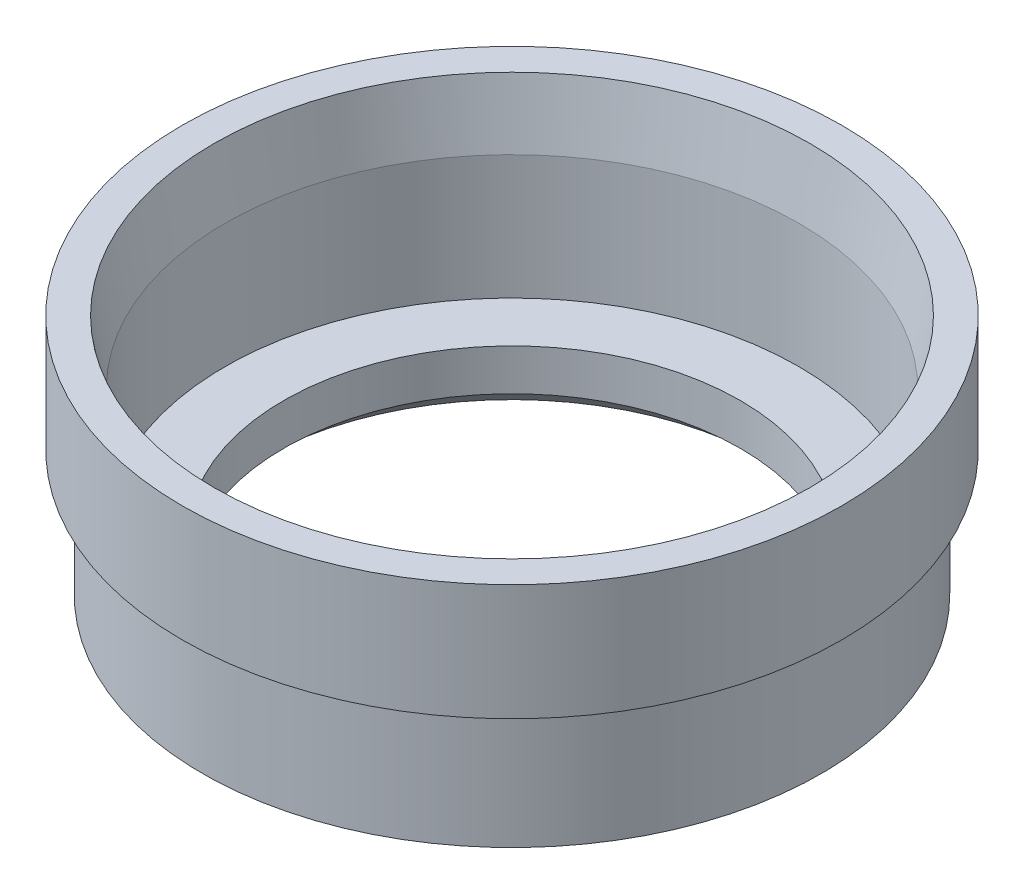
from build123d import *


with BuildPart() as part:
    # Sketch2 → Revolve1 (revolve)
    with BuildSketch(Plane.XY):
        Polygon((0, 8.639461868), (0, 5.245589646), (2.296170187, 3.205597118), (3.796170187, 3.205597118), (3.796170187, 4.205597118), (6.65, 4.205597118), (6.65, 14.505597118), (8.3, 14.505597118), (8.3, 24.014413354), (6.65, 24.014413354), (5.705888238, 24.014413354), (4.8, 18.810277156), (4.8, 8.639461868), align=None)
    revolve(axis=Axis((-18.7, 7.436212611, 0), (0, 1, 0)))


solid = part.part
